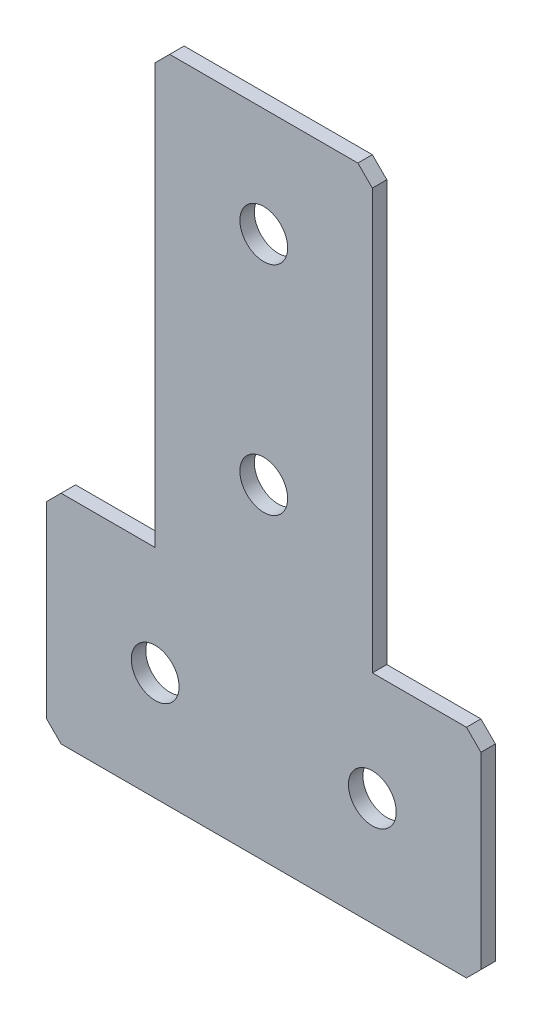
from build123d import *

# Parameters (mm, degrees)
EXTRUDE_1_DEPTH   = 2
HOLE_WIZARD_M61_D = 6.6
CHAMFER_1_SIZE    = 2


with BuildPart() as part:
    # Эскиз1 → Бобышка-Вытянуть1 (new body)
    with BuildSketch(Plane(origin=(0, 0, 0), x_dir=(1, 0, 0), z_dir=(0, 0, -1))):
        Polygon((-30, 90), (30, 90), (30, 60), (15, 60), (15, 0), (-15, 0), (-15, 60), (-30, 60), align=None)
    extrude(amount=EXTRUDE_1_DEPTH)

    # Отверстие с зазором M61 (through all)
    with Locations(Plane(origin=(0, 0, -2), x_dir=(1, 0, 0), z_dir=(0, 0, -1))):
        with Locations((0, 15), (-15, 75), (15, 75), (0, 45)):
            Hole(HOLE_WIZARD_M61_D / 2)

    # Фаска1
    chamfer_1_edges = [part.edges().sort_by_distance(p)[0] for p in [
        (-30, -60, -1),
        (-30, -90, -1),
        (30, -90, -1),
        (30, -60, -1),
        (15, 0, -1),
        (-15, 0, -1),
    ]]
    chamfer(chamfer_1_edges, length=CHAMFER_1_SIZE)


solid = part.part
